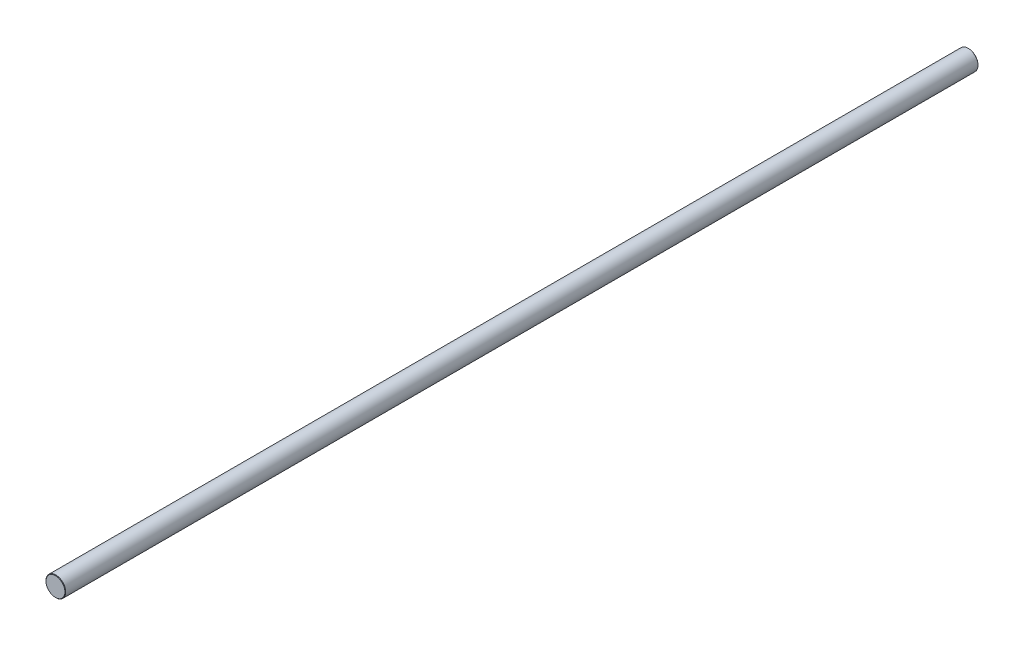
from build123d import *

# Parameters (mm, degrees)
SKETCH3_R                = 4
BOSS_EXTRUDE1_DEPTH      = 185
BOSS_EXTRUDE1_DEPTH_BACK = 185
CHAMFER1_SIZE            = 0.16


with BuildPart() as part:
    # Sketch3 → Boss-Extrude1 (new body, two sides)
    with BuildSketch(Plane.XY) as boss_extrude1_sk:
        Circle(SKETCH3_R)
    extrude(amount=BOSS_EXTRUDE1_DEPTH)
    extrude(boss_extrude1_sk.sketch, amount=-BOSS_EXTRUDE1_DEPTH_BACK)

    # Chamfer1
    chamfer1_edges = [part.edges().sort_by_distance(p)[0] for p in [
        (-4, 0, -185),
        (-4, 0, 185),
    ]]
    chamfer(chamfer1_edges, length=CHAMFER1_SIZE)


solid = part.part
